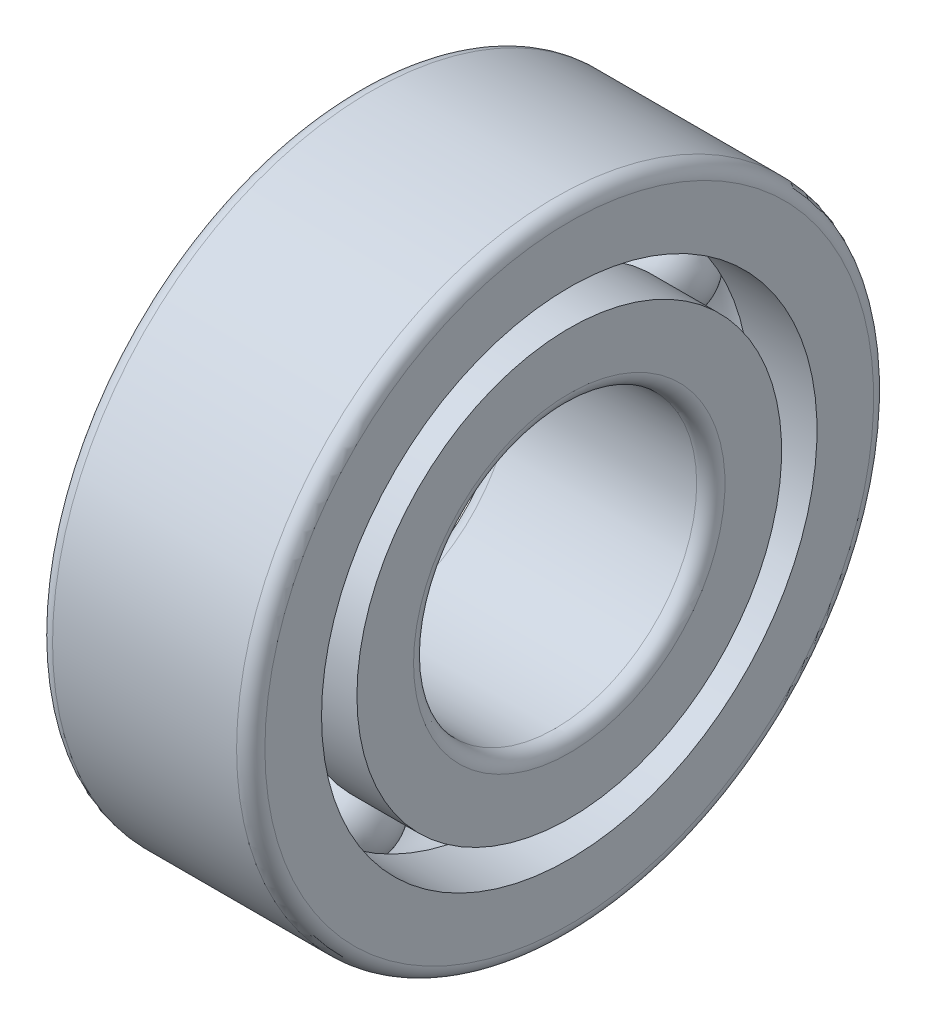
from build123d import *

# Parameters (mm, degrees)
FILLET1_R         = 1
FILLET2_R         = 1
CIRPATTERN2_COUNT = 12


with BuildPart() as part:
    # Sketch1 → Revolve3 (revolve)
    with BuildSketch(Plane.XY):
        with BuildLine():
            Line((0, 12.5), (0, 7.5))
            Line((0, 7.5), (4.772821971, 7.5))
            ThreePointArc((4.772821971, 7.5), (7.5, 9.25), (10.227178029, 7.5))
            Line((10.227178029, 7.5), (15, 7.5))
            Line((15, 7.5), (15, 12.5))
            Line((15, 12.5), (0, 12.5))
        make_face()
        with BuildLine():
            Line((0, 5), (0, 0))
            Line((0, 0), (15, 0))
            Line((15, 0), (15, 5))
            Line((15, 5), (10.227178029, 5))
            ThreePointArc((10.227178029, 5), (7.5, 3.25), (4.772821971, 5))
            Line((4.772821971, 5), (0, 5))
        make_face()
    revolve(axis=Axis((0, 22.5, 0), (1, 0, 0)))

    # Fillet1
    fillet1_edges = [part.edges().sort_by_distance(p)[0] for p in [
        (15, 45, 0),
        (0, 45, 0),
    ]]
    fillet(fillet1_edges, radius=FILLET1_R)

    # Fillet2
    fillet2_edges = [part.edges().sort_by_distance(p)[0] for p in [
        (0, 32.5, 0),
        (15, 32.5, 0),
    ]]
    fillet(fillet2_edges, radius=FILLET2_R)


with BuildPart() as body_2:
    # Sketch5 → Revolve4 (revolve)
    with BuildSketch(Plane(origin=(0, 22.5, 0), x_dir=(1, 0, 0), z_dir=(0, 1, 0))):
        with BuildLine():
            Line((10.5, 16.25), (4.5, 16.25))
            ThreePointArc((4.5, 16.25), (7.5, 19.25), (10.5, 16.25))
        make_face()
    revolve(axis=Axis((10.5, 22.5, -16.25), (-1, 0, 0)))


with BuildPart() as cirpattern2_1:
    # CirPattern2: pattern copy
    add(body_2.part.rotate(Axis((0, 22.5, 0), (1, 0, 0)), 1 * 360 / CIRPATTERN2_COUNT))


with BuildPart() as cirpattern2_2:
    # CirPattern2: pattern copy
    add(body_2.part.rotate(Axis((0, 22.5, 0), (1, 0, 0)), 2 * 360 / CIRPATTERN2_COUNT))


with BuildPart() as cirpattern2_3:
    # CirPattern2: pattern copy
    add(body_2.part.rotate(Axis((0, 22.5, 0), (1, 0, 0)), 3 * 360 / CIRPATTERN2_COUNT))


with BuildPart() as cirpattern2_4:
    # CirPattern2: pattern copy
    add(body_2.part.rotate(Axis((0, 22.5, 0), (1, 0, 0)), 4 * 360 / CIRPATTERN2_COUNT))


with BuildPart() as cirpattern2_5:
    # CirPattern2: pattern copy
    add(body_2.part.rotate(Axis((0, 22.5, 0), (1, 0, 0)), 5 * 360 / CIRPATTERN2_COUNT))


with BuildPart() as cirpattern2_6:
    # CirPattern2: pattern copy
    add(body_2.part.rotate(Axis((0, 22.5, 0), (1, 0, 0)), 6 * 360 / CIRPATTERN2_COUNT))


with BuildPart() as cirpattern2_7:
    # CirPattern2: pattern copy
    add(body_2.part.rotate(Axis((0, 22.5, 0), (1, 0, 0)), 7 * 360 / CIRPATTERN2_COUNT))


with BuildPart() as cirpattern2_8:
    # CirPattern2: pattern copy
    add(body_2.part.rotate(Axis((0, 22.5, 0), (1, 0, 0)), 8 * 360 / CIRPATTERN2_COUNT))


with BuildPart() as cirpattern2_9:
    # CirPattern2: pattern copy
    add(body_2.part.rotate(Axis((0, 22.5, 0), (1, 0, 0)), 9 * 360 / CIRPATTERN2_COUNT))


with BuildPart() as cirpattern2_10:
    # CirPattern2: pattern copy
    add(body_2.part.rotate(Axis((0, 22.5, 0), (1, 0, 0)), 10 * 360 / CIRPATTERN2_COUNT))


with BuildPart() as cirpattern2_11:
    # CirPattern2: pattern copy
    add(body_2.part.rotate(Axis((0, 22.5, 0), (1, 0, 0)), 11 * 360 / CIRPATTERN2_COUNT))


solid = Compound([part.part, body_2.part, cirpattern2_1.part, cirpattern2_2.part, cirpattern2_3.part, cirpattern2_4.part, cirpattern2_5.part, cirpattern2_6.part, cirpattern2_7.part, cirpattern2_8.part, cirpattern2_9.part, cirpattern2_10.part, cirpattern2_11.part])
